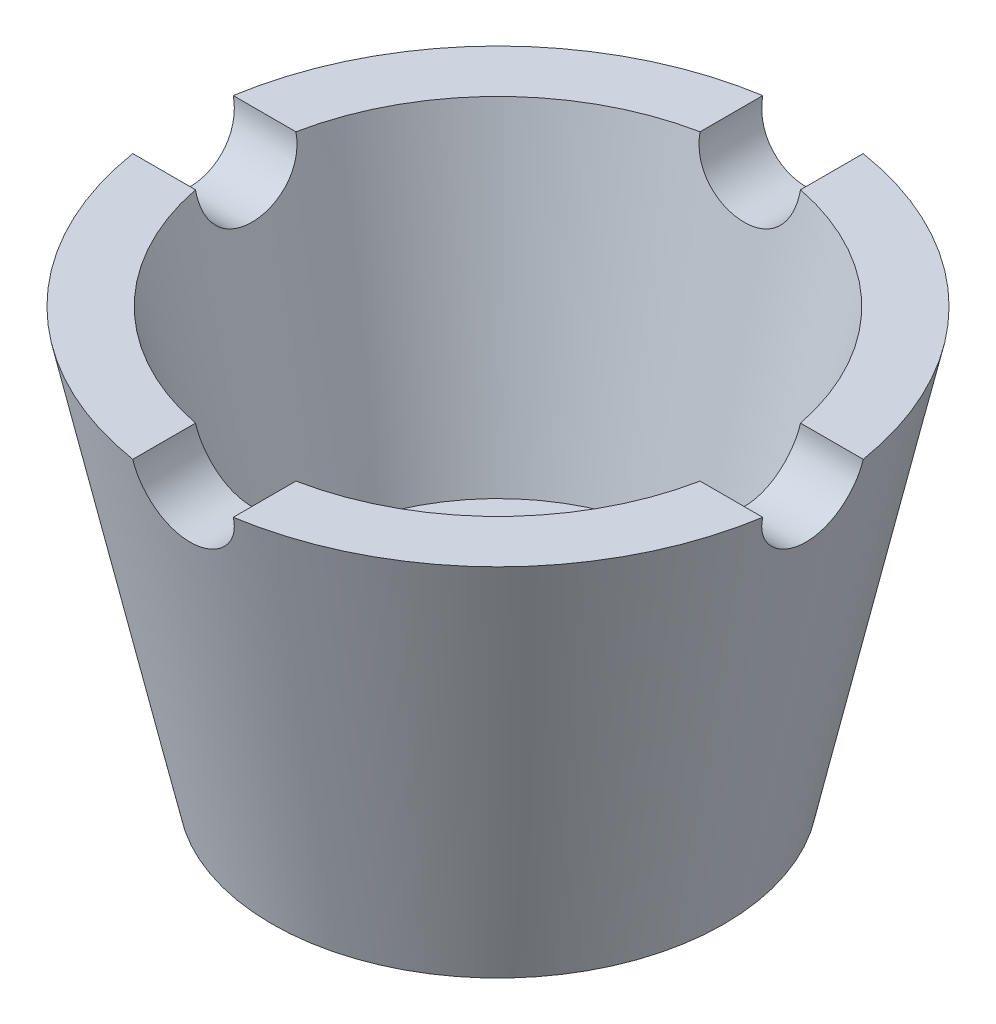
from build123d import *

# Parameters (mm, degrees)
CUT_EXTRUDE1_START = -40
SKETCH4_R          = 5
CUT_EXTRUDE1_DEPTH = 79
CIRPATTERN1_COUNT  = 4


with BuildPart() as part:
    # Sketch2 → Revolve1 (revolve)
    with BuildSketch(Plane.XY):
        Polygon((11, 0), (22.5, 0), (31.753664233, 42), (25.609760166, 42), (19, 12), (11, 12), align=None)
    revolve(axis=Axis((0, 0, 0), (0, 1, 0)))

    # Sketch4 → Cut-Extrude1 (cut)
    with BuildSketch(Plane.XY.offset(CUT_EXTRUDE1_START)):
        with Locations((0, 42)):
            Circle(SKETCH4_R)
    cut_extrude1 = extrude(amount=CUT_EXTRUDE1_DEPTH, mode=Mode.SUBTRACT)

    # CirPattern1: Cut-Extrude1 ×4 about axis
    cirpattern1_axis = Axis((0, 42, 0), (0, 1, 0))
    for i in range(1, CIRPATTERN1_COUNT):
        add(cut_extrude1.rotate(cirpattern1_axis, i * 360 / CIRPATTERN1_COUNT), mode=Mode.SUBTRACT)


solid = part.part
